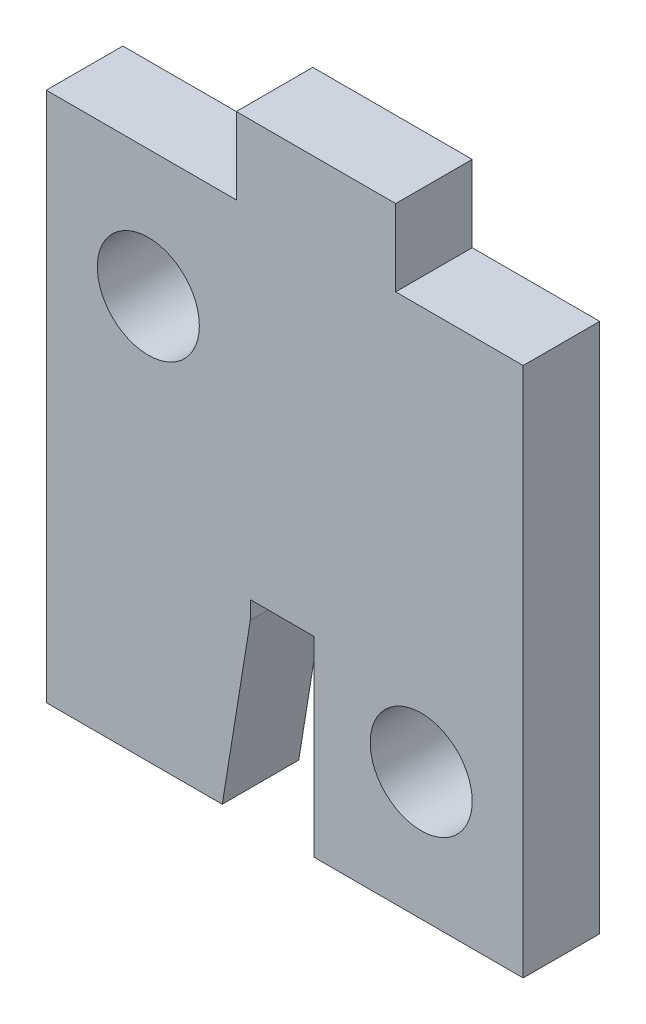
from build123d import *

# Parameters (mm, degrees)
BOSS_EXTRUDE1_DEPTH          = 3
SKETCH2_W                    = 7.45
SKETCH2_H                    = 3
CUT_EXTRUDE1_DEPTH           = 3
SKETCH3_W                    = 3
SKETCH3_H                    = 20.8
BOSS_EXTRUDE2_DEPTH          = 5
CUT_EXTRUDE2_REACH           = 5
F_4_0_4_DIAMETER_HOLE1_D     = 4
F_4_0_4_DIAMETER_HOLE1_DEPTH = 3


with BuildPart() as part:
    # Sketch1 → Boss-Extrude1 (new body)
    with BuildSketch(Plane.XY):
        Polygon((-13.7, 0), (-5.7, 0), (-5.7, 7.5), (-3.2, 7.5), (-3.2, 0), (0, 0), (0, 23.8), (-13.7, 23.8), align=None)
    extrude(amount=BOSS_EXTRUDE1_DEPTH)

    # Sketch2 → Cut-Extrude1 (cut)
    with BuildSketch(Plane.XY.offset(3)):
        with Locations((-9.975, 22.3)):
            Rectangle(SKETCH2_W, SKETCH2_H)
    extrude(amount=-CUT_EXTRUDE1_DEPTH, mode=Mode.SUBTRACT)

    # Sketch3 → Boss-Extrude2 (add)
    with BuildSketch(Plane(origin=(0, 0, 0), x_dir=(0, 0, -1), z_dir=(1, 0, 0))):
        with Locations((-1.5, 10.4)):
            Rectangle(SKETCH3_W, SKETCH3_H)
    extrude(amount=BOSS_EXTRUDE2_DEPTH)

    # Sketch4 → Cut-Extrude2 (cut, up to next)
    with BuildSketch(Plane.XY.offset(3), mode=Mode.PRIVATE) as cut_extrude2_sk1:
        Polygon((-5.7, 0), (-6.8, 0), (-5.7, 6.8), align=None)
    cut_extrude2_tool1 = extrude(cut_extrude2_sk1.sketch, amount=-CUT_EXTRUDE2_REACH, mode=Mode.PRIVATE) & part.part
    add(cut_extrude2_tool1.solids().sort_by_distance((-6.066667, 2.266667, 3))[0], mode=Mode.SUBTRACT)

    # Ø4.0 (4) Diameter Hole1
    with Locations(Plane.XY.offset(3)):
        with Locations((-9.7, 15.8), (1, 5)):
            Hole(F_4_0_4_DIAMETER_HOLE1_D / 2, depth=F_4_0_4_DIAMETER_HOLE1_DEPTH)


solid = part.part
